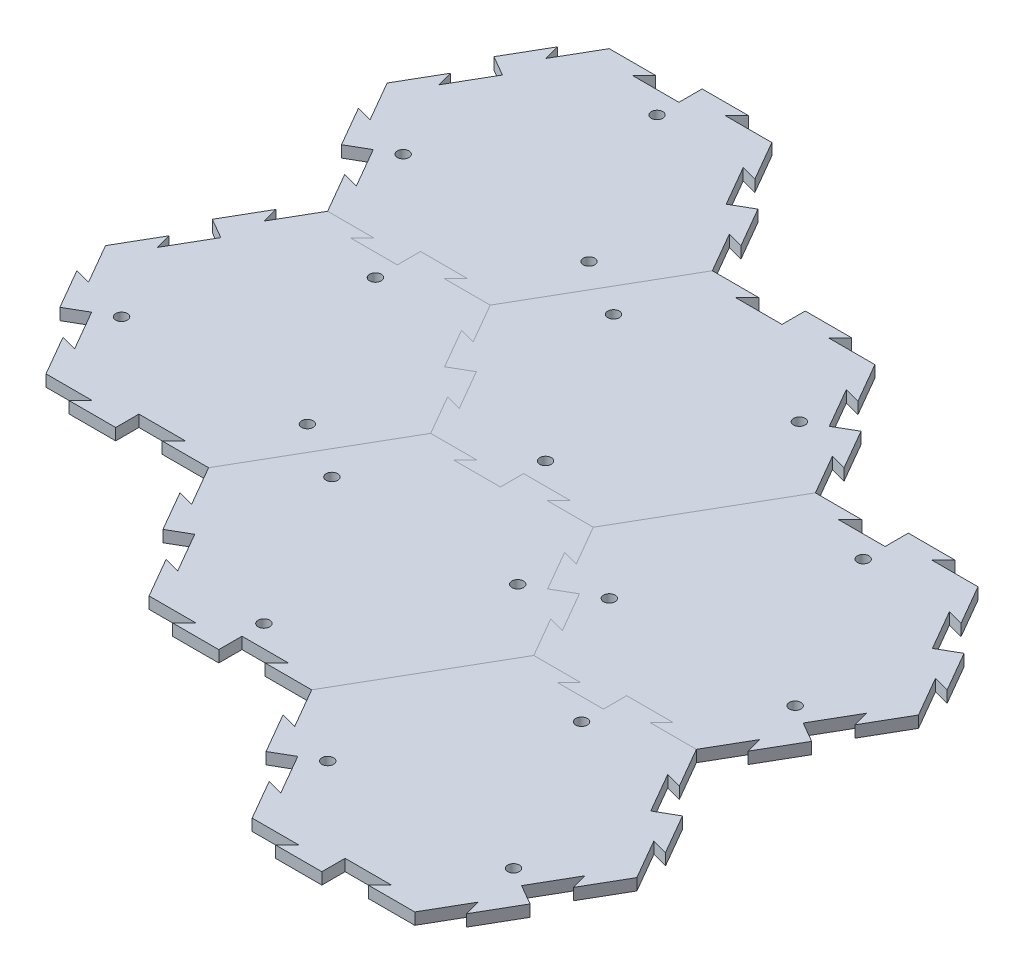
from build123d import *

# Parameters (mm, degrees)
BOSS_EXTRUDE1_DEPTH = 6.35
SKETCH9_R           = 3.175
CUT_EXTRUDE3_DEPTH  = 7.35
CIRPATTERN6_COUNT   = 3
CUT_EXTRUDE4_DEPTH  = 7.35
BOSS_EXTRUDE4_DEPTH = 6.35
CIRPATTERN7_COUNT   = 6
CUT_EXTRUDE5_DEPTH  = 7.35
BOSS_EXTRUDE5_DEPTH = 6.35
CIRPATTERN8_COUNT   = 6
CUT_EXTRUDE6_DEPTH  = 7.35
BOSS_EXTRUDE6_DEPTH = 6.35
CIRPATTERN9_COUNT   = 6
LPATTERN1_COUNT     = 2
LPATTERN1_PITCH     = 153.979316882


with BuildPart() as part:
    # Sketch1 → Boss-Extrude1 (new body)
    with BuildSketch(Plane(origin=(0, 0, 0), x_dir=(1, 0, 0), z_dir=(0, 1, 0))):
        Polygon((88.9, 0), (44.45, 76.989658396), (-44.45, 76.989658396), (-88.9, 0), (-44.45, -76.989658396), (44.45, -76.989658396), align=None)
    extrude(amount=-BOSS_EXTRUDE1_DEPTH)

    # Sketch9 → Cut-Extrude3 (cut, through all)
    with BuildSketch(Plane(origin=(0, 0, 0), x_dir=(1, 0, 0), z_dir=(0, 1, 0))):
        with Locations((-50.8, -29.329393675)):
            Circle(SKETCH9_R)
    cut_extrude3 = extrude(amount=-CUT_EXTRUDE3_DEPTH, mode=Mode.SUBTRACT)

    # CirPattern6: Cut-Extrude3 ×3 about axis
    cirpattern6_axis = Axis((0, 0, 0), (0, 1, 0))
    for i in range(1, CIRPATTERN6_COUNT):
        add(cut_extrude3.rotate(cirpattern6_axis, i * 360 / CIRPATTERN6_COUNT), mode=Mode.SUBTRACT)


with BuildPart() as body_2:
    # Mirror3: mirrored copy
    add(part.part.mirror(Plane(origin=(44.45, -6.35, 76.989658396), x_dir=(-0.5, 0, 0.866025404), z_dir=(0.866025404, 0, 0.5))))


with BuildPart() as part_1:
    add(part.part)

    # Sketch10 → Cut-Extrude4 (cut, through all)
    with BuildSketch(Plane(origin=(0, 0, 0), x_dir=(1, 0, 0), z_dir=(0, 1, 0))):
        Polygon((57.15, 54.99261314), (48.475738686, 57.316874454), (61.175738686, 35.319829198), (66.675, 38.494829198), align=None)
    cut_extrude4 = extrude(amount=-CUT_EXTRUDE4_DEPTH, mode=Mode.SUBTRACT)

    # Sketch11 → Boss-Extrude4 (add)
    with BuildSketch(Plane(origin=(0, 0, 0), x_dir=(1, 0, 0), z_dir=(0, 1, 0))):
        Polygon((66.675, 38.494829198), (72.174261314, 41.669829198), (84.874261314, 19.672783942), (76.2, 21.997045256), align=None)
    boss_extrude4 = extrude(amount=-BOSS_EXTRUDE4_DEPTH)

    # CirPattern7: Cut-Extrude4, Boss-Extrude4 ×6 about axis, 1 skipped
    cirpattern7_axis = Axis((0, 0, 0), (0, 1, 0))
    add([cut_extrude4.rotate(cirpattern7_axis, i * 360 / CIRPATTERN7_COUNT) for i in range(1, CIRPATTERN7_COUNT) if i not in (5,)], mode=Mode.SUBTRACT)
    add([boss_extrude4.rotate(cirpattern7_axis, i * 360 / CIRPATTERN7_COUNT) for i in range(1, CIRPATTERN7_COUNT) if i not in (5,)])


with BuildPart() as body_3:
    # Mirror4: mirrored copy
    add(body_2.part.mirror(Plane(origin=(222.25, -6.35, 76.989658396), x_dir=(-0.5, 0, 0.866025404), z_dir=(0.866025404, 0, 0.5))))

    # Sketch16 → Cut-Extrude6 (cut, through all)
    with BuildSketch(Plane(origin=(0, 0, 0), x_dir=(1, 0, 0), z_dir=(0, 1, 0))):
        Polygon((323.85, -98.986703653), (315.175738686, -96.662442339), (327.875738686, -118.659487595), (333.375, -115.484487595), align=None)
    cut_extrude6 = extrude(amount=-CUT_EXTRUDE6_DEPTH, mode=Mode.SUBTRACT)

    # Sketch17 → Boss-Extrude6 (add)
    with BuildSketch(Plane(origin=(0, 0, 0), x_dir=(1, 0, 0), z_dir=(0, 1, 0))):
        Polygon((333.375, -115.484487595), (338.874261314, -112.309487595), (351.574261314, -134.306532851), (342.9, -131.982271537), align=None)
    boss_extrude6 = extrude(amount=-BOSS_EXTRUDE6_DEPTH)

    # CirPattern9: Cut-Extrude6, Boss-Extrude6 ×6 about axis, 1 skipped
    cirpattern9_axis = Axis((266.7, 0, 153.979316793), (0, 1, 0))
    add([cut_extrude6.rotate(cirpattern9_axis, i * 360 / CIRPATTERN9_COUNT) for i in range(1, CIRPATTERN9_COUNT) if i not in (2,)], mode=Mode.SUBTRACT)
    add([boss_extrude6.rotate(cirpattern9_axis, i * 360 / CIRPATTERN9_COUNT) for i in range(1, CIRPATTERN9_COUNT) if i not in (2,)])


with BuildPart() as body_2_1:
    add(body_2.part)

    # Sketch13 → Cut-Extrude5 (cut, through all)
    with BuildSketch(Plane(origin=(0, 0, 0), x_dir=(1, 0, 0), z_dir=(0, 1, 0))):
        Polygon((190.5, -21.997045256), (181.825738686, -19.672783942), (194.525738686, -41.669829198), (200.025, -38.494829198), align=None)
    cut_extrude5 = extrude(amount=-CUT_EXTRUDE5_DEPTH, mode=Mode.SUBTRACT)

    # Sketch14 → Boss-Extrude5 (add)
    with BuildSketch(Plane(origin=(0, 0, 0), x_dir=(1, 0, 0), z_dir=(0, 1, 0))):
        Polygon((200.025, -38.494829198), (205.524261314, -35.319829198), (218.224261314, -57.316874454), (209.55, -54.99261314), align=None)
    boss_extrude5 = extrude(amount=-BOSS_EXTRUDE5_DEPTH)

    # CirPattern8: Cut-Extrude5, Boss-Extrude5 ×6 about axis, 2 skipped
    cirpattern8_axis = Axis((133.35, 0, 76.989658396), (0, 1, 0))
    add([cut_extrude5.rotate(cirpattern8_axis, i * 360 / CIRPATTERN8_COUNT) for i in range(1, CIRPATTERN8_COUNT) if i not in (2, 5)], mode=Mode.SUBTRACT)
    add([boss_extrude5.rotate(cirpattern8_axis, i * 360 / CIRPATTERN8_COUNT) for i in range(1, CIRPATTERN8_COUNT) if i not in (2, 5)])


with BuildPart() as lpattern1_1:
    # LPattern1: pattern copy
    add(part_1.part.moved(Location(Vector(0, 0, -1) * (1 * LPATTERN1_PITCH))))


with BuildPart() as lpattern1_2:
    # LPattern1: pattern copy
    add(body_3.part.moved(Location(Vector(0, 0, -1) * (1 * LPATTERN1_PITCH))))


with BuildPart() as lpattern1_3:
    # LPattern1: pattern copy
    add(body_2_1.part.moved(Location(Vector(0, 0, -1) * (1 * LPATTERN1_PITCH))))


solid = Compound([part_1.part, body_3.part, body_2_1.part, lpattern1_1.part, lpattern1_2.part, lpattern1_3.part])
